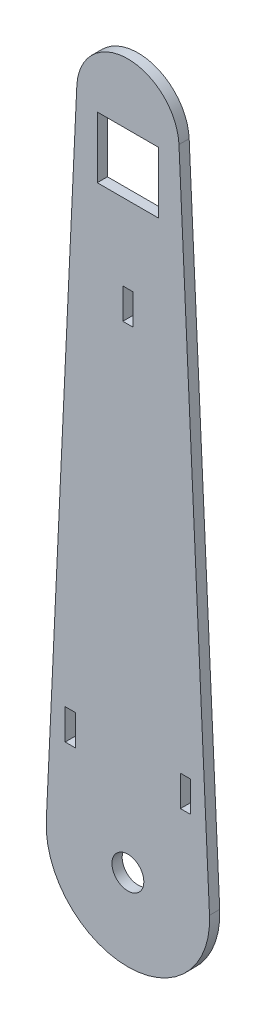
from build123d import *

# Parameters (mm, degrees)
SKETCH1_R           = 4.953
SKETCH1_W           = 3.175
SKETCH1_H           = 9.525
SKETCH1_W_2         = 19.05
SKETCH1_H_2         = 19.05
BOSS_EXTRUDE1_DEPTH = 3.175


with BuildPart() as part:
    # Sketch1 → Boss-Extrude1 (new body)
    with BuildSketch(Plane.XY):
        with BuildLine():
            Line((-25.372181386, 1.188449288), (-15.875, 203.943595206))
            ThreePointArc((-15.875, 203.943595206), (0, 219.092405697), (15.875, 203.943595206))
            Line((15.875, 203.943595206), (25.372181386, 1.188449288))
            ThreePointArc((25.372181386, 1.188449288), (0, -25.4), (-25.372181386, 1.188449288))
        make_face()
        Circle(SKETCH1_R, mode=Mode.SUBTRACT)
        with Locations((-17.9197, 30.1625)):
            Rectangle(SKETCH1_W, SKETCH1_H, mode=Mode.SUBTRACT)
        with Locations((0, 152.4)):
            Rectangle(SKETCH1_W, SKETCH1_H, mode=Mode.SUBTRACT)
        with Locations((17.9197, 30.1625)):
            Rectangle(SKETCH1_W, SKETCH1_H, mode=Mode.SUBTRACT)
        with Locations((0, 190.5)):
            Rectangle(SKETCH1_W_2, SKETCH1_H_2, mode=Mode.SUBTRACT)
    extrude(amount=BOSS_EXTRUDE1_DEPTH)


solid = part.part
